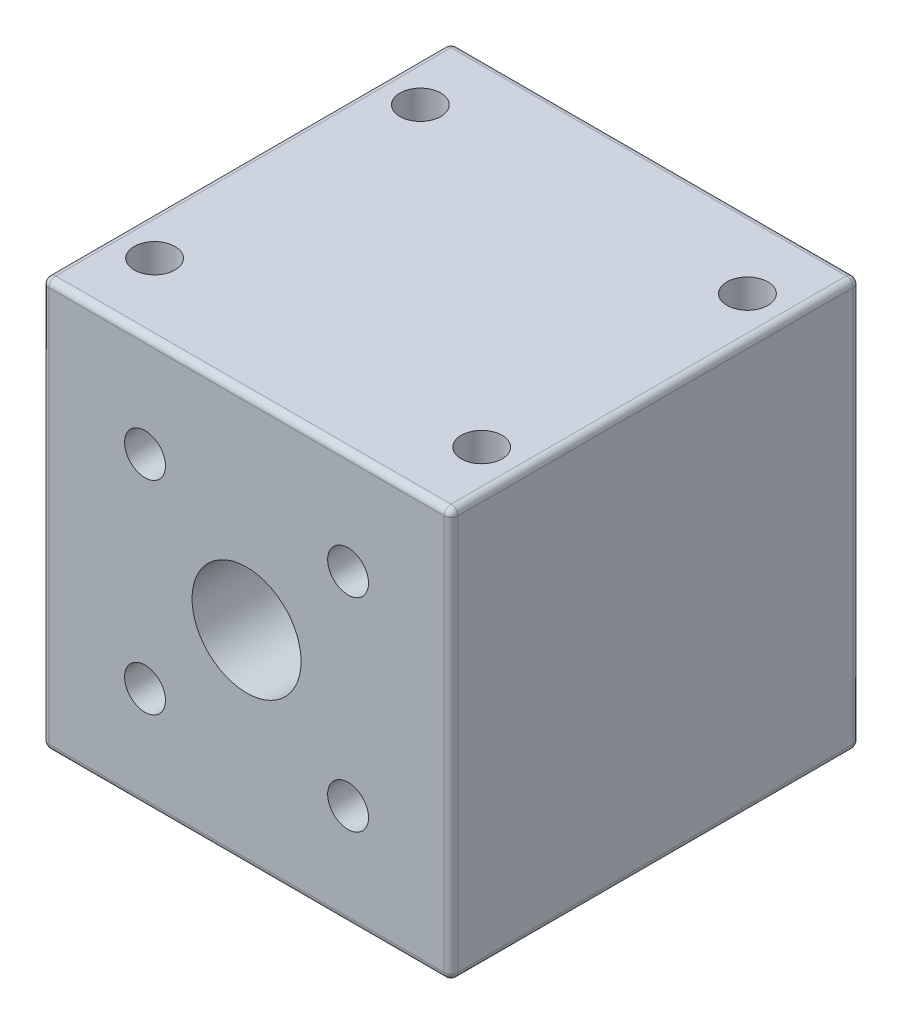
from build123d import *

# Parameters (mm, degrees)
CROQUIS1_R              = 4
CROQUIS1_R_2            = 1.5
SALIENTE_EXTRUIR1_DEPTH = 30
CROQUIS2_R              = 1.5
CORTAR_EXTRUIR1_DEPTH   = 30
REDONDEO1_R             = 0.5
REDONDEO2_R             = 0.5


with BuildPart() as part:
    # Croquis1 → Saliente-Extruir1 (new body)
    with BuildSketch(Plane.XY):
        with BuildLine():
            Line((-14.5, -15), (14.5, -15))
            ThreePointArc((14.5, -15), (14.853553391, -14.853553391), (15, -14.5))
            Line((15, -14.5), (15, 14.5))
            ThreePointArc((15, 14.5), (14.853553391, 14.853553391), (14.5, 15))
            Line((14.5, 15), (-14.5, 15))
            ThreePointArc((-14.5, 15), (-14.853553391, 14.853553391), (-15, 14.5))
            Line((-15, 14.5), (-15, -14.5))
            ThreePointArc((-15, -14.5), (-14.853553391, -14.853553391), (-14.5, -15))
        make_face()
        Circle(CROQUIS1_R, mode=Mode.SUBTRACT)
        with Locations((-7.45, 7.45)):
            Circle(CROQUIS1_R_2, mode=Mode.SUBTRACT)
        with Locations((7.45, 7.45)):
            Circle(CROQUIS1_R_2, mode=Mode.SUBTRACT)
        with Locations((-7.45, -7.45)):
            Circle(CROQUIS1_R_2, mode=Mode.SUBTRACT)
        with Locations((7.45, -7.45)):
            Circle(CROQUIS1_R_2, mode=Mode.SUBTRACT)
    extrude(amount=SALIENTE_EXTRUIR1_DEPTH)

    # Croquis2 → Cortar-Extruir1 (cut)
    with BuildSketch(Plane.XZ.offset(15)):
        with Locations((-12, 24.75)):
            Circle(CROQUIS2_R)
        with Locations((12, 24.75)):
            Circle(CROQUIS2_R)
        with Locations((12, 5.25)):
            Circle(CROQUIS2_R)
        with Locations((-12, 5.25)):
            Circle(CROQUIS2_R)
    extrude(amount=-CORTAR_EXTRUIR1_DEPTH, mode=Mode.SUBTRACT)

    # Redondeo1
    redondeo1_edges = [part.edges().sort_by_distance(p)[0] for p in [
        (15, 0, 30),
        (0, 15, 30),
        (-15, 0, 30),
        (0, -15, 30),
    ]]
    fillet(redondeo1_edges, radius=REDONDEO1_R)

    # Redondeo2
    redondeo2_edges = [part.edges().sort_by_distance(p)[0] for p in [
        (15, 0, 0),
        (0, -15, 0),
        (-15, 0, 0),
        (0, 15, 0),
    ]]
    fillet(redondeo2_edges, radius=REDONDEO2_R)


solid = part.part
